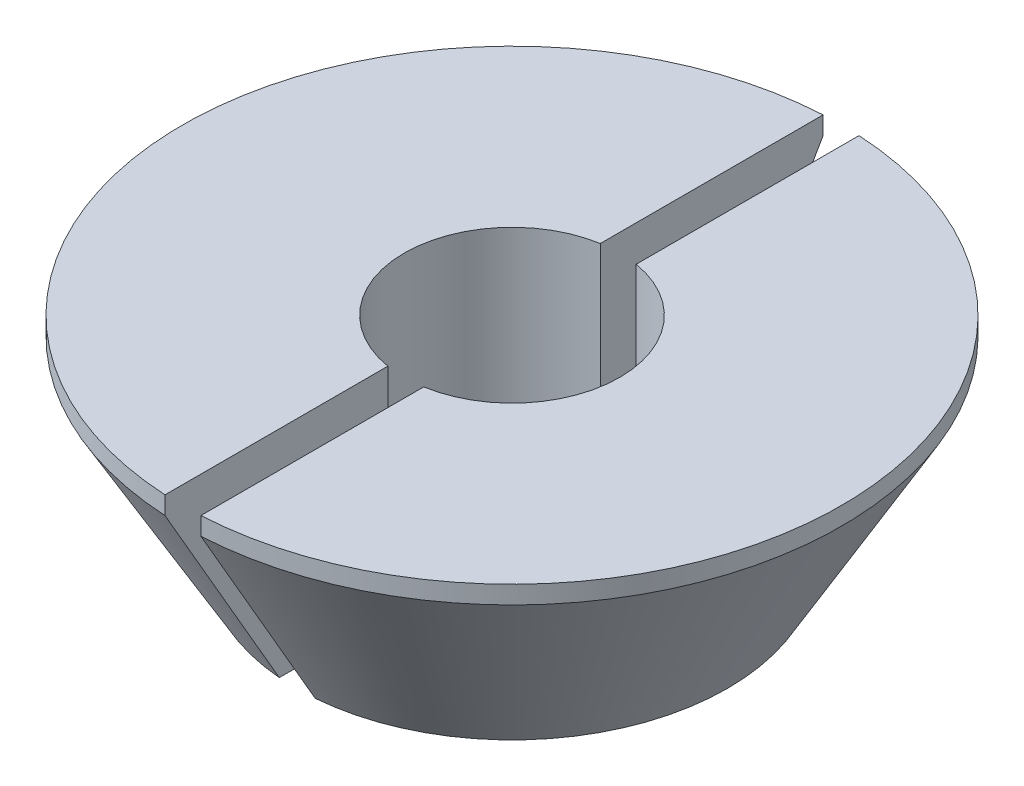
from build123d import *

# Parameters (mm, degrees)
SKETCH2_W          = 0.5
SKETCH2_H          = 10
CUT_EXTRUDE1_DEPTH = 4


with BuildPart() as part:
    # Sketch1 → Revolve1 (revolve)
    with BuildSketch(Plane.XY):
        Polygon((1.5, 0), (3, 0), (4.58771324, 2.75), (4.58771324, 3), (1.5, 3), align=None)
    revolve(axis=Axis((0, 0, 0), (0, 1, 0)))

    # Sketch2 → Cut-Extrude1 (cut, through all)
    with BuildSketch(Plane(origin=(0, 3, 0), x_dir=(1, 0, 0), z_dir=(0, 1, 0))):
        Rectangle(SKETCH2_W, SKETCH2_H)
    extrude(amount=-CUT_EXTRUDE1_DEPTH, mode=Mode.SUBTRACT)


solid = part.part
